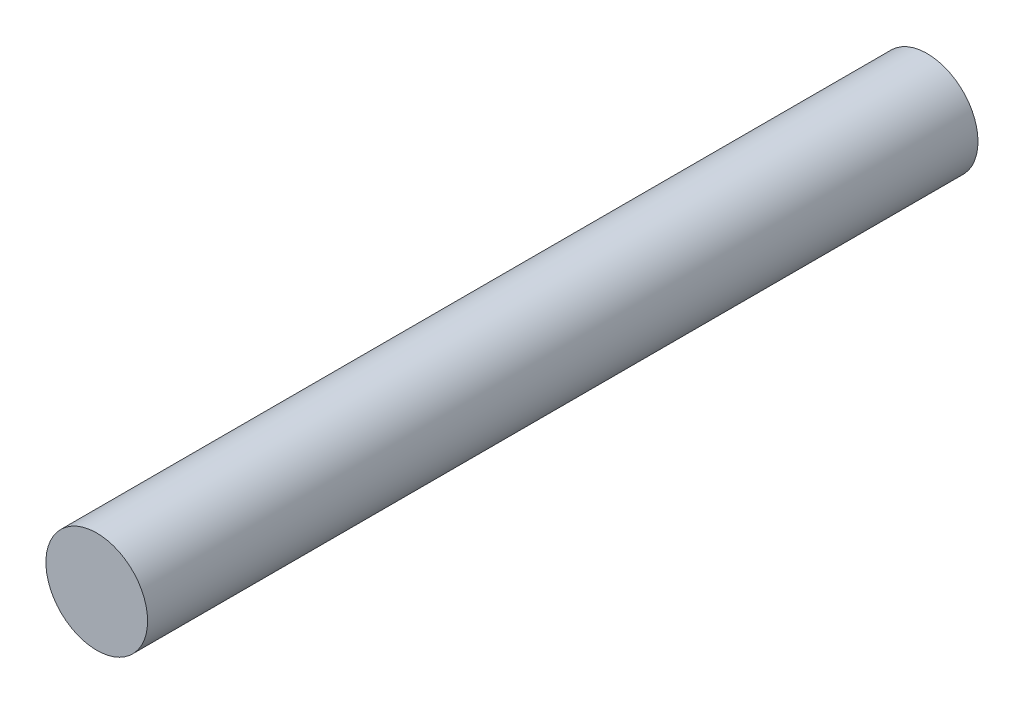
from build123d import *

# Parameters (mm, degrees)
ESQUISSE1_R      = 3
EXTRUSION1_DEPTH = 49


with BuildPart() as part:
    # Esquisse1 → Extrusion1 (new body)
    with BuildSketch(Plane.XY):
        Circle(ESQUISSE1_R)
    extrude(amount=EXTRUSION1_DEPTH)


solid = part.part
